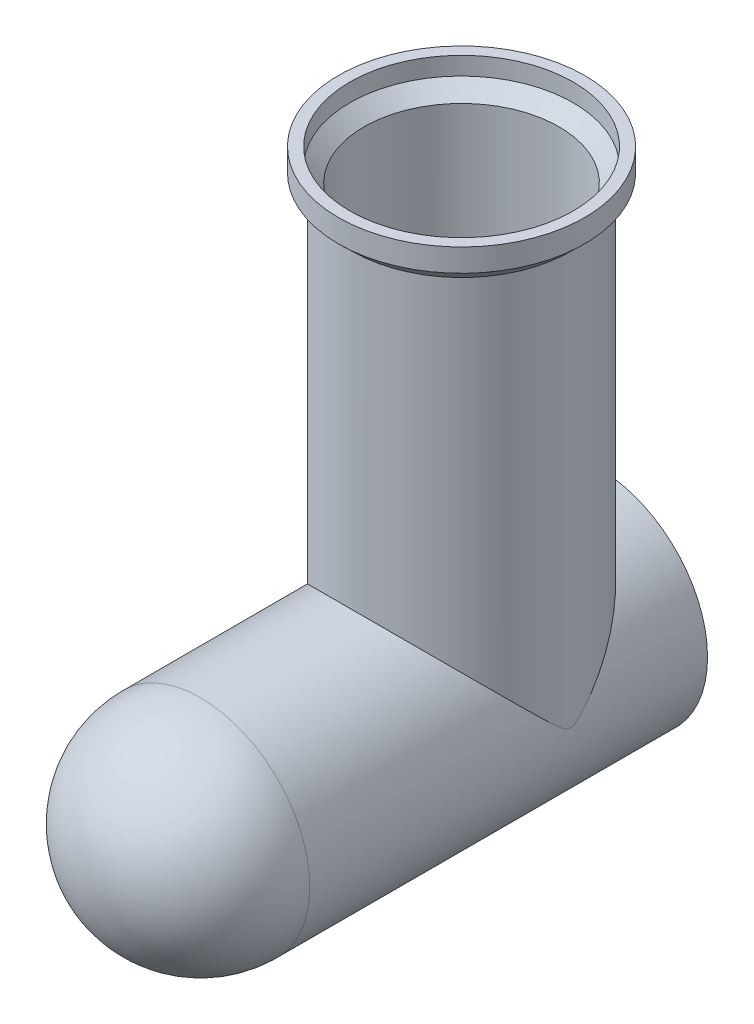
from build123d import *

# Parameters (mm, degrees)
SKETCH1_R           = 47.85
BOSS_EXTRUDE1_DEPTH = 222.25
SKETCH2_R           = 47.75
BOSS_EXTRUDE2_DEPTH = 183.95
FILLET1_R           = 47.85
SHELL1_T            = -5


with BuildPart() as part:
    # Sketch1 → Boss-Extrude1 (new body)
    with BuildSketch(Plane.XY):
        Circle(SKETCH1_R)
    extrude(amount=BOSS_EXTRUDE1_DEPTH)

    # Sketch2 → Boss-Extrude2 (add)
    with BuildSketch(Plane(origin=(0, 183.95, 0), x_dir=(1, 0, 0), z_dir=(0, 1, 0))):
        with Locations(Location((0, -60, 0), (0, 0, 270))):
            Circle(SKETCH2_R)
    extrude(amount=-BOSS_EXTRUDE2_DEPTH)

    # Sketch5 → Revolve3 (revolve)
    with BuildSketch(Plane(origin=(0, 0, 0), x_dir=(0, 0, -1), z_dir=(1, 0, 0)), mode=Mode.PRIVATE) as revolve3_sk:
        Polygon((-60, 183.95), (-12.25, 183.95), (-6.025, 189.95), (-6.025, 199.95), (-60, 199.95), align=None)
    revolve(revolve3_sk.sketch.rotate(Axis((0, 199.95, 60), (0, -1, 0)), 180), axis=Axis((0, 199.95, 60), (0, -1, 0)))

    # Fillet1
    fillet1_edges = [part.edges().sort_by_distance(p)[0] for p in [
        (-47.85, 0, 222.25),
    ]]
    fillet(fillet1_edges, radius=FILLET1_R)

    # Shell1
    shell1_openings = [part.faces().sort_by_distance(p)[0] for p in [
        (0, 199.95, 60),
        (0, 0, 0),
    ]]
    offset(amount=SHELL1_T, openings=shell1_openings, kind=Kind.INTERSECTION)


solid = part.part
